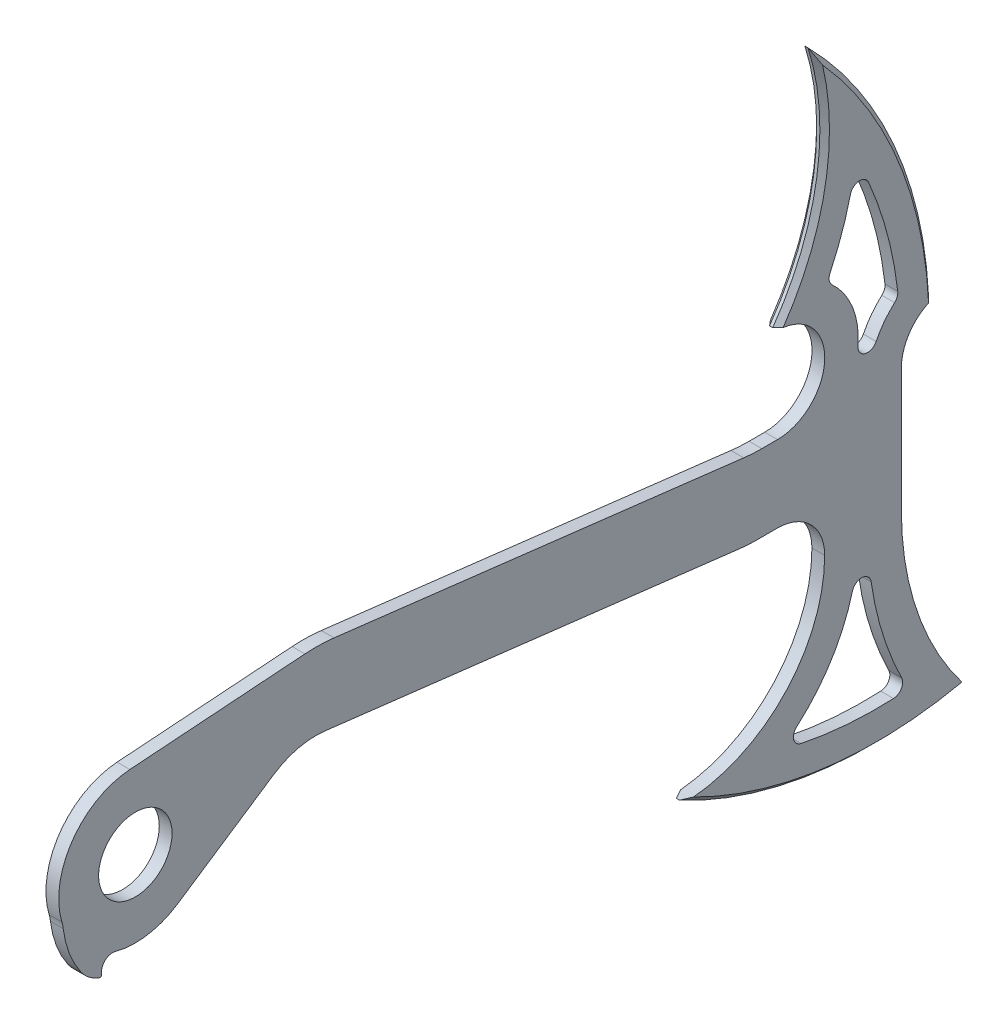
from build123d import *

# Parameters (mm, degrees)
SKETCH1_R            = 36.5125
BOSS_EXTRUDE1_DEPTH  = 12.7
BOSS_EXTRUDE2_DEPTH  = 12.7
FILLET2_R            = 50.8
CUT_EXTRUDE3_DEPTH   = 13.7
BOSS_EXTRUDE3_DEPTH  = 12.7
BOSS_EXTRUDE4_DEPTH  = 12.7
FILLET3_R            = 152.4
BOSS_EXTRUDE7_DEPTH  = 12.7
FILLET7_R            = 1.5875
FILLET8_R            = 38.1
BOSS_EXTRUDE10_DEPTH = 12.7
CUT_EXTRUDE4_DEPTH   = 13.7000001
CHAMFER3_SIZE        = 4.7625
CUT_EXTRUDE5_DEPTH   = 13.7000001
BOSS_EXTRUDE12_DEPTH = 12.7
CUT_EXTRUDE7_DEPTH   = 13.7000001
FILLET9_R            = 9.525
CHAMFER5_SIZE        = 4.7625


with BuildPart() as part:
    # Sketch1 → Boss-Extrude1 (new body)
    with BuildSketch(Plane(origin=(0, 0, 0), x_dir=(0, 0, -1), z_dir=(1, 0, 0))):
        with BuildLine():
            ThreePointArc((-5.457335057, 76.004325496), (-72.099059144, -24.661015197), (42.233639175, -63.425229381))
            Line((42.233639175, -63.425229381), (137.371483247, -0.074770619))
            ThreePointArc((137.371483247, -0.074770619), (161.913577951, 10.617806594), (188.639208153, 12.16257526))
            Line((188.639208153, 12.16257526), (609.6, -38.1))
            Line((609.6, -38.1), (762, -38.1))
            Line((762, -38.1), (762, 38.1))
            Line((762, 38.1), (614.133028178, 38.1))
            Line((614.133028178, 38.1), (197.673293886, 87.82515052))
            ThreePointArc((197.673293886, 87.82515052), (183.198162724, 88.857638671), (168.690452307, 88.508650992))
            Line((168.690452307, 88.508650992), (-5.457335057, 76.004325496))
        make_face()
        Circle(SKETCH1_R, mode=Mode.SUBTRACT)
        with BuildLine():
            Line((65.991135768, 38.075696093), (65.991135768, 38.1))
            Line((65.991135768, 38.1), (66.012869164, 38.1))
            ThreePointArc((66.012869164, 38.1), (66.002001816, 38.087848628), (65.991135768, 38.075696093))
        make_face(mode=Mode.SUBTRACT)
    extrude(amount=BOSS_EXTRUDE1_DEPTH)

    # Sketch2 → Boss-Extrude2 (add)
    with BuildSketch(Plane(origin=(12.7, 0, 0), x_dir=(0, 0, -1), z_dir=(1, 0, 0))):
        with BuildLine():
            ThreePointArc((838.2, -241.3), (781.676406492, -146.608847566), (762, -38.1))
            Line((762, -38.1), (711.2, -38.1))
            ThreePointArc((711.2, -38.1), (663.188122847, -151.161248155), (558.8, -215.9))
            ThreePointArc((558.8, -215.9), (694.145313376, -276.50155286), (838.2, -241.3))
        make_face()
    extrude(amount=-BOSS_EXTRUDE2_DEPTH)

    # Fillet2
    fillet2_edges = [part.edges().sort_by_distance(p)[0] for p in [
        (6.35, -38.1, -711.2),
    ]]
    fillet(fillet2_edges, radius=FILLET2_R)

    # Sketch5 → Cut-Extrude3 (cut, through all)
    with BuildSketch(Plane(origin=(12.7, 0, 0), x_dir=(0, 0, -1), z_dir=(1, 0, 0))):
        with BuildLine():
            ThreePointArc((706.341071076, -120.97396451), (712.16258099, -105.404310368), (714.140419987, -88.9))
            Line((714.140419987, -88.9), (746.906762977, -88.9))
            ThreePointArc((746.906762977, -88.9), (769.01471884, -166.253931311), (809.283275536, -235.901872727))
            ThreePointArc((809.283275536, -235.901872727), (701.723342893, -257.979336354), (597.765297452, -222.63420517))
            ThreePointArc((597.765297452, -222.63420517), (660.810042683, -181.156636745), (706.341071076, -120.97396451))
        make_face()
    extrude(amount=-CUT_EXTRUDE3_DEPTH, mode=Mode.SUBTRACT)

    # Sketch6 → Boss-Extrude3 (add)
    with BuildSketch(Plane(origin=(12.7, 0, 0), x_dir=(0, 0, -1), z_dir=(1, 0, 0))):
        with BuildLine():
            ThreePointArc((695.102416733, -257.458581374), (701.752213076, -257.981145264), (708.415272379, -258.291798028))
            ThreePointArc((708.415272379, -258.291798028), (727.449025604, -194.709598183), (736.425982813, -128.949472436))
            ThreePointArc((736.425982813, -128.949472436), (743.290173942, -191.94221299), (750.671382161, -254.876466362))
            ThreePointArc((750.671382161, -254.876466362), (750.696835025, -255.086067605), (750.722282144, -255.295669545))
            ThreePointArc((750.722282144, -255.295669545), (756.982833491, -254.109298059), (763.204419609, -252.733127053))
            ThreePointArc((763.204419609, -252.733127053), (753.71236553, -170.864991909), (745.096638992, -88.9))
            Line((745.096638992, -88.9), (715.964600354, -88.9))
            ThreePointArc((715.964600354, -88.9), (693.107033352, -174.003371278), (640.674115832, -244.82597595))
            ThreePointArc((640.674115832, -244.82597595), (647.424643267, -247.249366442), (654.254150602, -249.440318672))
            ThreePointArc((654.254150602, -249.440318672), (698.625698601, -191.01101247), (724.053660032, -122.190689362))
            ThreePointArc((724.053660032, -122.190689362), (715.248453644, -191.038268325), (695.102416733, -257.458581374))
        make_face()
    extrude(amount=-BOSS_EXTRUDE3_DEPTH)

    # Sketch9 → Boss-Extrude4 (add)
    with BuildSketch(Plane(origin=(12.7, 0, 0), x_dir=(0, 0, -1), z_dir=(1, 0, 0))):
        with BuildLine():
            Line((715.964600354, -88.9), (714.140419987, -88.9))
            ThreePointArc((714.140419987, -88.9), (712.16258099, -105.404310368), (706.341071076, -120.97396451))
            ThreePointArc((706.341071076, -120.97396451), (702.230291918, -128.561844655), (697.828033656, -135.984415138))
            ThreePointArc((697.828033656, -135.984415138), (703.838864444, -134.153585185), (706.433482305, -139.876345292))
            ThreePointArc((706.433482305, -139.876345292), (712.600934388, -114.650286537), (715.964600354, -88.9))
        make_face()
        with BuildLine():
            Line((746.906762977, -88.9), (745.096638992, -88.9))
            ThreePointArc((745.096638992, -88.9), (747.942218661, -116.919782575), (750.890210196, -144.928975443))
            ThreePointArc((750.890210196, -144.928975443), (754.605324005, -139.769897323), (760.138617968, -142.900522752))
            ThreePointArc((760.138617968, -142.900522752), (752.376743186, -116.181055108), (746.906762977, -88.9))
        make_face()
        with BuildLine():
            ThreePointArc((717.474254342, -147.13087482), (720.23377617, -145.526704715), (722.110050465, -148.108935769))
            ThreePointArc((722.110050465, -148.108935769), (723.284620056, -135.165017901), (724.053660032, -122.190689362))
            ThreePointArc((724.053660032, -122.190689362), (721.086941255, -134.745987681), (717.474254342, -147.13087482))
        make_face()
        with BuildLine():
            ThreePointArc((734.298451278, -153.410765103), (736.673157602, -151.303816062), (739.031324159, -153.429260691))
            ThreePointArc((739.031324159, -153.429260691), (737.718891682, -141.190405495), (736.425982813, -128.949472436))
            ThreePointArc((736.425982813, -128.949472436), (735.537630459, -141.195375427), (734.298451278, -153.410765103))
        make_face()
    extrude(amount=-BOSS_EXTRUDE4_DEPTH)

    # Fillet3
    fillet3_edges = [part.edges().sort_by_distance(p)[0] for p in [
        (6.35, 38.1, -614.133028178),
        (6.35, -38.1, -609.6),
    ]]
    fillet(fillet3_edges, radius=FILLET3_R)

    # Sketch12 → Boss-Extrude7 (add)
    with BuildSketch(Plane(origin=(12.7, 0, 0), x_dir=(0, 0, -1), z_dir=(1, 0, 0))):
        with BuildLine():
            ThreePointArc((-47.625, -82.48891971), (-40.169757324, -86.365230831), (-32.401896994, -89.569412029))
            ThreePointArc((-32.401896994, -89.569412029), (-31.300162168, -77.426361921), (-19.722011237, -73.603547963))
            ThreePointArc((-19.722011237, -73.603547963), (-52.02518736, -55.676026081), (-72.099059144, -24.661015197))
            ThreePointArc((-72.099059144, -24.661015197), (-64.441659044, -55.513168803), (-47.625, -82.48891971))
        make_face()
    extrude(amount=-BOSS_EXTRUDE7_DEPTH)

    # Fillet7
    fillet7_edges = [part.edges().sort_by_distance(p)[0] for p in [
        (6.35, -89.569412029, 32.401896994),
    ]]
    fillet(fillet7_edges, radius=FILLET7_R)

    # Fillet8
    fillet8_edges = [part.edges().sort_by_distance(p)[0] for p in [
        (6.35, -24.661015197, 72.099059144),
        (6.35, -82.48891971, 47.625),
    ]]
    fillet(fillet8_edges, radius=FILLET8_R)

    # Sketch15 → Boss-Extrude10 (add)
    with BuildSketch(Plane(origin=(12.7, 0, 0), x_dir=(0, 0, -1), z_dir=(1, 0, 0))):
        with BuildLine():
            Line((638.81, 38.1), (762, 38.1))
            ThreePointArc((762, 38.1), (770.752664188, 65.412382723), (793.75, 82.55))
            ThreePointArc((793.75, 82.55), (758.948762545, 230.090705656), (673.9381574, 355.6))
            ThreePointArc((673.9381574, 355.6), (682.637545611, 239.712462422), (638.81, 132.08))
            ThreePointArc((638.81, 132.08), (685.8, 85.09), (638.81, 38.1))
        make_face()
    extrude(amount=-BOSS_EXTRUDE10_DEPTH)

    # Sketch16 → Cut-Extrude4 (cut, through all)
    with BuildSketch(Plane(origin=(12.7, 0, 0), x_dir=(0, 0, -1), z_dir=(1, 0, 0))):
        with BuildLine():
            ThreePointArc((687.773313141, 148.769676683), (712.260370665, 117.609998545), (718.869593607, 78.534946402))
            ThreePointArc((718.869593607, 78.534946402), (725.827656809, 68.576243579), (736.909876293, 73.553674318))
            ThreePointArc((736.909876293, 73.553674318), (746.406416661, 88.456750816), (758.93185326, 100.922680628))
            ThreePointArc((758.93185326, 100.922680628), (744.477147892, 173.156921439), (716.554967432, 241.326385946))
            ThreePointArc((716.554967432, 241.326385946), (706.095105413, 193.825649057), (687.773313141, 148.769676683))
        make_face()
    extrude(amount=-CUT_EXTRUDE4_DEPTH, mode=Mode.SUBTRACT)

    # Chamfer3
    chamfer3_edges = [part.edges().sort_by_distance(p)[0] for p in [
        (0, 230.090705656, -758.948762545),
        (12.7, 230.090705656, -758.948762545),
        (0, 239.712462422, -682.637545611),
        (12.7, 239.712462422, -682.637545611),
        (0, -276.50155286, -694.145313376),
        (12.7, -276.50155286, -694.145313376),
    ]]
    chamfer(chamfer3_edges, length=CHAMFER3_SIZE)

    # Sketch17 → Cut-Extrude5 (cut, through all)
    with BuildSketch(Plane(origin=(12.7, 0, 0), x_dir=(0, 0, -1), z_dir=(1, 0, 0))):
        with BuildLine():
            Line((644.290419987, -38.1), (762, -38.1))
            Line((762, -38.1), (838.2, -241.3))
            ThreePointArc((838.2, -241.3), (694.145313376, -276.50155286), (558.8, -215.9))
            Line((558.8, -215.9), (644.290419987, -38.1))
        make_face()
    extrude(amount=-CUT_EXTRUDE5_DEPTH, mode=Mode.SUBTRACT)

    # Sketch20 → Boss-Extrude12 (add)
    with BuildSketch(Plane(origin=(12.7, 0, 0), x_dir=(0, 0, -1), z_dir=(1, 0, 0))):
        with BuildLine():
            Line((762, -85.09), (762, -38.1))
            Line((762, -38.1), (638.726685676, -38.1))
            ThreePointArc((638.726685676, -38.1), (671.953633324, -51.863052352), (685.716685676, -85.09))
            ThreePointArc((685.716685676, -85.09), (645.024708616, -185.228916137), (546.016685676, -228.6))
            ThreePointArc((546.016685676, -228.6), (682.34684765, -272.675091389), (825.5, -266.7))
            ThreePointArc((825.5, -266.7), (778.33263031, -181.285688703), (762, -85.09))
        make_face()
    extrude(amount=-BOSS_EXTRUDE12_DEPTH)

    # Sketch21 → Cut-Extrude7 (cut, through all)
    with BuildSketch(Plane(origin=(12.7, 0, 0), x_dir=(0, 0, -1), z_dir=(1, 0, 0))):
        with BuildLine():
            ThreePointArc((731.922263923, -130.990436649), (723.037545397, -122.827129654), (713.278830952, -129.922571626))
            ThreePointArc((713.278830952, -129.922571626), (686.933048916, -186.739671508), (642.440908991, -230.816111416))
            ThreePointArc((642.440908991, -230.816111416), (705.21470493, -241.684815921), (768.922454248, -241.714330998))
            ThreePointArc((768.922454248, -241.714330998), (745.406702262, -188.028447135), (731.922263923, -130.990436649))
        make_face()
    extrude(amount=-CUT_EXTRUDE7_DEPTH, mode=Mode.SUBTRACT)

    # Fillet9
    fillet9_edges = [part.edges().sort_by_distance(p)[0] for p in [
        (6.35, 148.769676683, -687.773313141),
        (6.35, 241.326385946, -716.554967432),
        (6.35, 100.922680628, -758.93185326),
        (6.35, -241.714330998, -768.922454248),
        (6.35, -230.816111416, -642.440908991),
    ]]
    fillet(fillet9_edges, radius=FILLET9_R)

    # Chamfer5
    chamfer5_edges = [part.edges().sort_by_distance(p)[0] for p in [
        (0, -272.675091389, -682.34684765),
        (12.7, -272.675091389, -682.34684765),
    ]]
    chamfer(chamfer5_edges, length=CHAMFER5_SIZE)


solid = part.part
